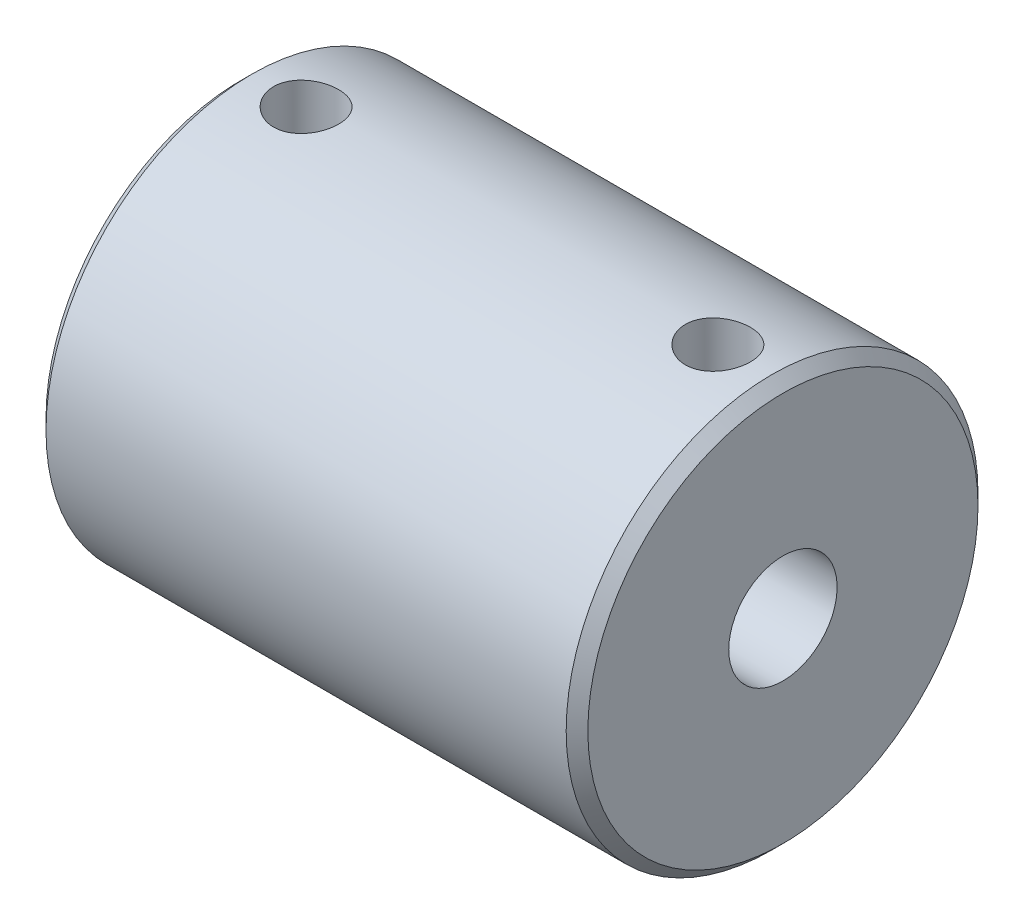
from build123d import *

# Parameters (mm, degrees)
CUT_EXTRUDE1_REACH = 11.5
SKETCH2_R          = 1.5
CHAMFER1_SIZE      = 0.5


with BuildPart() as part:
    # Sketch1 → Revolve1 (revolve)
    with BuildSketch(Plane.XY):
        Polygon((-12.5, 4), (0, 4), (0, 2.5), (12.5, 2.5), (12.5, 9.5), (-12.5, 9.5), align=None)
    revolve(axis=Axis((-12.5, 0, 0), (1, 0, 0)))

    # Sketch2 → Cut-Extrude1 (cut, up to next)
    with BuildSketch(Plane(origin=(0, 0, 0), x_dir=(1, 0, 0), z_dir=(0, 1, 0)), mode=Mode.PRIVATE) as cut_extrude1_sk1:
        with Locations((-9.5, 0)):
            Circle(SKETCH2_R)
    cut_extrude1_tool1 = extrude(cut_extrude1_sk1.sketch, amount=CUT_EXTRUDE1_REACH, mode=Mode.PRIVATE) & part.part
    add(cut_extrude1_tool1.solids().sort_by_distance((-9.5, 0, 0))[0], mode=Mode.SUBTRACT)
    # Sketch2 → Cut-Extrude1 (cut, up to next)
    with BuildSketch(Plane(origin=(0, 0, 0), x_dir=(1, 0, 0), z_dir=(0, 1, 0)), mode=Mode.PRIVATE) as cut_extrude1_sk2:
        with Locations((9.5, 0)):
            Circle(SKETCH2_R)
    cut_extrude1_tool2 = extrude(cut_extrude1_sk2.sketch, amount=CUT_EXTRUDE1_REACH, mode=Mode.PRIVATE) & part.part
    add(cut_extrude1_tool2.solids().sort_by_distance((9.5, 0, 0))[0], mode=Mode.SUBTRACT)

    # Chamfer1
    chamfer1_edges = [part.edges().sort_by_distance(p)[0] for p in [
        (-12.5, -9.5, 0),
        (12.5, -9.5, 0),
    ]]
    chamfer(chamfer1_edges, length=CHAMFER1_SIZE)


solid = part.part
